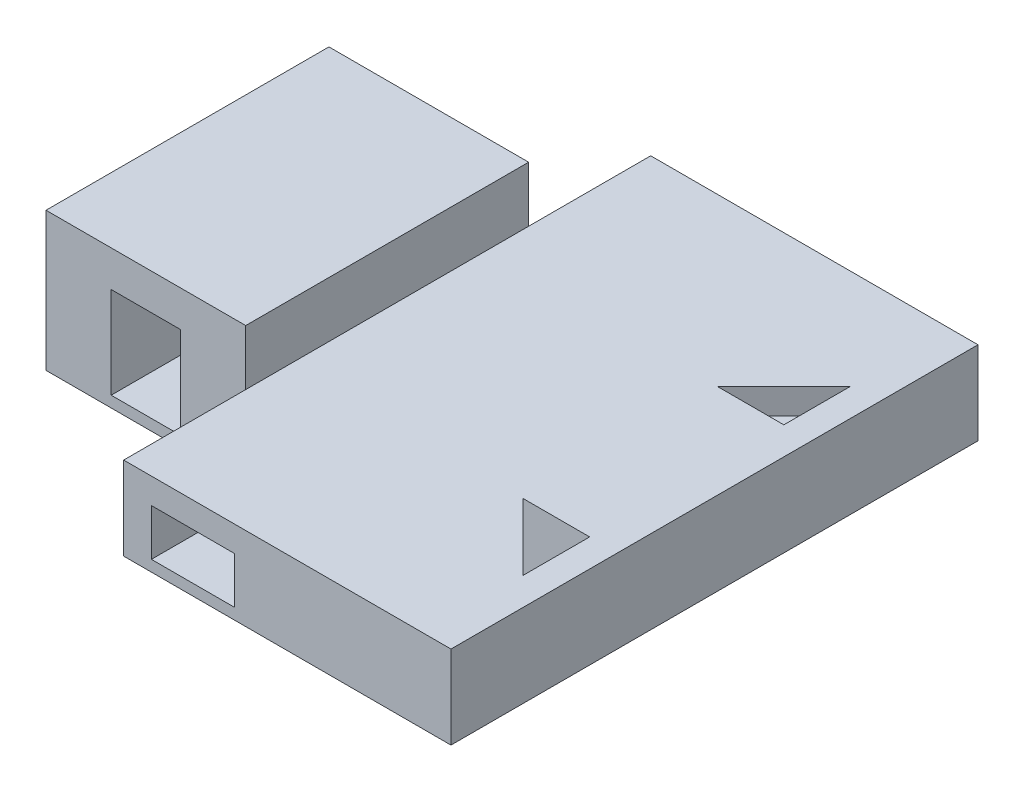
from build123d import *

# Parameters (mm, degrees)
SKETCH1_W           = 90
SKETCH1_H           = 95
BOSS_EXTRUDE3_DEPTH = 15
SKETCH5_W           = 15
SKETCH5_H           = 8.4
CUT_EXTRUDE3_DEPTH  = 40
SKETCH7_W           = 95
SKETCH7_H           = 15
BOSS_EXTRUDE4_DEPTH = 5
CUT_EXTRUDE7_DEPTH  = 13
SKETCH12_W          = 15
SKETCH12_H          = 8.4
CUT_EXTRUDE8_DEPTH  = 20
CUT_EXTRUDE9_DEPTH  = 13
SKETCH14_W          = 15
SKETCH14_H          = 8.4
CUT_EXTRUDE11_DEPTH = 20
SKETCH15_W          = 36
SKETCH15_H          = 15
CUT_EXTRUDE12_DEPTH = 22
SKETCH16_W          = 36
SKETCH16_H          = 15
CUT_EXTRUDE13_DEPTH = 22
SKETCH17_W          = 36
SKETCH17_H          = 51
BOSS_EXTRUDE5_DEPTH = 10
SKETCH18_W          = 12.5
SKETCH18_H          = 16.5
CUT_EXTRUDE14_DEPTH = 100
SKETCH19_W          = 15
SKETCH19_H          = 8.4
CUT_EXTRUDE15_DEPTH = 100


with BuildPart() as part:
    # Sketch1 → Boss-Extrude3 (new body)
    with BuildSketch(Plane(origin=(0, 0, 0), x_dir=(1, 0, 0), z_dir=(0, 1, 0))):
        Rectangle(SKETCH1_W, SKETCH1_H)
    extrude(amount=BOSS_EXTRUDE3_DEPTH)

    # Sketch5 → Cut-Extrude3 (cut)
    with BuildSketch(Plane(origin=(45, 0, 0), x_dir=(0, 0, -1), z_dir=(1, 0, 0))):
        with Locations((0.9, 6.2)):
            Rectangle(SKETCH5_W, SKETCH5_H)
    extrude(amount=-CUT_EXTRUDE3_DEPTH, mode=Mode.SUBTRACT)

    # Sketch7 → Boss-Extrude4 (add)
    with BuildSketch(Plane(origin=(45, 0, 0), x_dir=(0, 0, -1), z_dir=(1, 0, 0))):
        with Locations((0, 7.5)):
            Rectangle(SKETCH7_W, SKETCH7_H)
    extrude(amount=BOSS_EXTRUDE4_DEPTH)

    # Sketch10 → Cut-Extrude7 (cut)
    with BuildSketch(Plane(origin=(0, 15, 0), x_dir=(1, 0, 0), z_dir=(0, 1, 0))):
        Polygon((33, -17.5), (45, -17.5), (45, -29.5), align=None)
    extrude(amount=-CUT_EXTRUDE7_DEPTH, mode=Mode.SUBTRACT)

    # Sketch12 → Cut-Extrude8 (cut)
    with BuildSketch(Plane(origin=(7.75, 0, -7.75), x_dir=(-0.707106781, 0, -0.707106781), z_dir=(0.707106781, 0, -0.707106781))):
        with Locations((-44.20889245, 6.2)):
            Rectangle(SKETCH12_W, SKETCH12_H)
    extrude(amount=-CUT_EXTRUDE8_DEPTH, mode=Mode.SUBTRACT)

    # Sketch13 → Cut-Extrude9 (cut)
    with BuildSketch(Plane(origin=(0, 15, 0), x_dir=(1, 0, 0), z_dir=(0, 1, 0))):
        Polygon((33, 17.5), (45, 17.5), (45, 29.5), align=None)
    extrude(amount=-CUT_EXTRUDE9_DEPTH, mode=Mode.SUBTRACT)

    # Sketch14 → Cut-Extrude11 (cut)
    with BuildSketch(Plane(origin=(7.75, 0, 7.75), x_dir=(0.707106781, 0, -0.707106781), z_dir=(0.707106781, 0, 0.707106781))):
        with Locations((44.20889245, 6.2)):
            Rectangle(SKETCH14_W, SKETCH14_H)
    extrude(amount=-CUT_EXTRUDE11_DEPTH, mode=Mode.SUBTRACT)

    # Sketch15 → Cut-Extrude12 (cut)
    with BuildSketch(Plane.XY.offset(47.5)):
        with Locations((-27, 7.5)):
            Rectangle(SKETCH15_W, SKETCH15_H)
    extrude(amount=-CUT_EXTRUDE12_DEPTH, mode=Mode.SUBTRACT)

    # Sketch16 → Cut-Extrude13 (cut)
    with BuildSketch(Plane(origin=(0, 0, -47.5), x_dir=(-1, 0, 0), z_dir=(0, 0, -1))):
        with Locations((27, 7.5)):
            Rectangle(SKETCH16_W, SKETCH16_H)
    extrude(amount=-CUT_EXTRUDE13_DEPTH, mode=Mode.SUBTRACT)

    # Sketch17 → Boss-Extrude5 (add)
    with BuildSketch(Plane(origin=(0, 15, 0), x_dir=(1, 0, 0), z_dir=(0, 1, 0))):
        with Locations((-27, 0)):
            Rectangle(SKETCH17_W, SKETCH17_H)
    extrude(amount=BOSS_EXTRUDE5_DEPTH)

    # Sketch18 → Cut-Extrude14 (cut)
    with BuildSketch(Plane(origin=(0, 0, -25.5), x_dir=(-1, 0, 0), z_dir=(0, 0, -1))):
        with Locations((27, 10.25)):
            Rectangle(SKETCH18_W, SKETCH18_H)
    extrude(amount=-CUT_EXTRUDE14_DEPTH, mode=Mode.SUBTRACT)

    # Sketch19 → Cut-Extrude15 (cut)
    with BuildSketch(Plane(origin=(0, 0, -47.5), x_dir=(-1, 0, 0), z_dir=(0, 0, -1))):
        with Locations((-3.5, 6.2)):
            Rectangle(SKETCH19_W, SKETCH19_H)
    extrude(amount=-CUT_EXTRUDE15_DEPTH, mode=Mode.SUBTRACT)


solid = part.part
